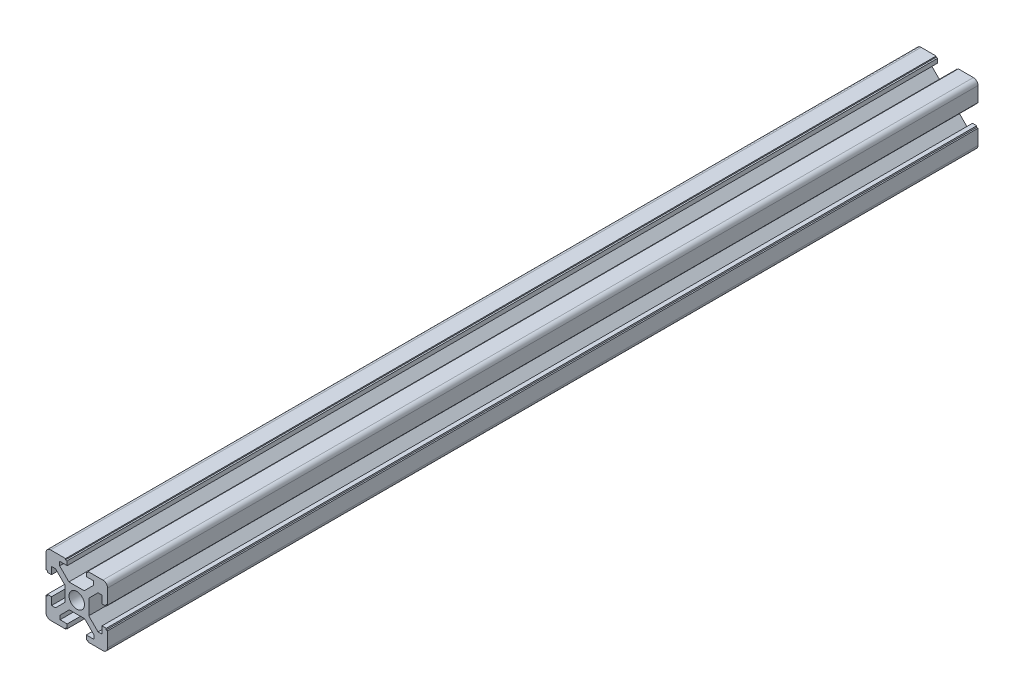
from build123d import *

# Parameters (mm, degrees)
SKETCH1_R           = 2.5
BOSS_EXTRUDE1_DEPTH = 283


with BuildPart() as part:
    # Sketch1 → Boss-Extrude1 (new body)
    with BuildSketch(Plane.XY):
        with BuildLine():
            Line((14.316619525, 10.387216168), (13.029112559, 10.387216168))
            Line((13.029112559, 10.387216168), (13.029112559, 12.855371932))
            Line((13.029112559, 12.855371932), (11.656738465, 12.855371932))
            Line((11.656738465, 12.855371932), (11.656738465, 12.336659272))
            Line((11.656738465, 12.336659272), (11.229112559, 12.336659272))
            Line((11.229112559, 12.336659272), (11.229112559, 7.521203168))
            ThreePointArc((11.229112559, 7.521203168), (11.668452387, 6.460542996), (12.729112559, 6.021203168))
            Line((12.729112559, 6.021203168), (17.624436699, 6.021203168))
            Line((17.624436699, 6.021203168), (17.624436699, 6.382997838))
            Line((17.624436699, 6.382997838), (18.129112559, 6.382997838))
            Line((18.129112559, 6.382997838), (18.129112559, 7.755371932))
            Line((18.129112559, 7.755371932), (15.794230869, 7.755371932))
            Line((15.794230869, 7.755371932), (15.794230869, 9.042878898))
            Line((15.794230869, 9.042878898), (18.806723903, 12.055371932))
            Line((18.806723903, 12.055371932), (23.784775289, 12.055371932))
            Line((23.784775289, 12.055371932), (26.797268323, 9.042878898))
            Line((26.797268323, 9.042878898), (26.797268323, 7.755371932))
            Line((26.797268323, 7.755371932), (24.329112559, 7.755371932))
            Line((24.329112559, 7.755371932), (24.329112559, 6.382997838))
            Line((24.329112559, 6.382997838), (24.847825219, 6.382997838))
            Line((24.847825219, 6.382997838), (24.847825219, 6.021203168))
            Line((24.847825219, 6.021203168), (29.729112559, 6.021203168))
            ThreePointArc((29.729112559, 6.021203168), (30.789772731, 6.460542996), (31.229112559, 7.521203168))
            Line((31.229112559, 7.521203168), (31.229112559, 12.350696072))
            Line((31.229112559, 12.350696072), (30.801486653, 12.350696072))
            Line((30.801486653, 12.350696072), (30.801486653, 12.855371932))
            Line((30.801486653, 12.855371932), (29.429112559, 12.855371932))
            Line((29.429112559, 12.855371932), (29.429112559, 10.520490242))
            Line((29.429112559, 10.520490242), (28.141605593, 10.520490242))
            Line((28.141605593, 10.520490242), (25.129112559, 13.532983276))
            Line((25.129112559, 13.532983276), (25.129112559, 18.511034662))
            Line((25.129112559, 18.511034662), (28.141605593, 21.523527696))
            Line((28.141605593, 21.523527696), (29.429112559, 21.523527696))
            Line((29.429112559, 21.523527696), (29.429112559, 19.055371932))
            Line((29.429112559, 19.055371932), (30.801486653, 19.055371932))
            Line((30.801486653, 19.055371932), (30.801486653, 19.574084592))
            Line((30.801486653, 19.574084592), (31.229112559, 19.574084592))
            Line((31.229112559, 19.574084592), (31.229112559, 24.389540696))
            ThreePointArc((31.229112559, 24.389540696), (30.789772731, 25.450200868), (29.729112559, 25.889540696))
            Line((29.729112559, 25.889540696), (24.833788419, 25.889540696))
            Line((24.833788419, 25.889540696), (24.833788419, 25.527746026))
            Line((24.833788419, 25.527746026), (24.329112559, 25.527746026))
            Line((24.329112559, 25.527746026), (24.329112559, 24.155371932))
            Line((24.329112559, 24.155371932), (26.663994249, 24.155371932))
            Line((26.663994249, 24.155371932), (26.663994249, 22.867864966))
            Line((26.663994249, 22.867864966), (23.651501215, 19.855371932))
            Line((23.651501215, 19.855371932), (18.673449829, 19.855371932))
            Line((18.673449829, 19.855371932), (15.660956795, 22.867864966))
            Line((15.660956795, 22.867864966), (15.660956795, 24.155371932))
            Line((15.660956795, 24.155371932), (18.129112559, 24.155371932))
            Line((18.129112559, 24.155371932), (18.129112559, 25.527746026))
            Line((18.129112559, 25.527746026), (17.610399899, 25.527746026))
            Line((17.610399899, 25.527746026), (17.610399899, 25.889540696))
            Line((17.610399899, 25.889540696), (12.729112559, 25.889540696))
            ThreePointArc((12.729112559, 25.889540696), (11.668452387, 25.450200868), (11.229112559, 24.389540696))
            Line((11.229112559, 24.389540696), (11.229112559, 19.560047792))
            Line((11.229112559, 19.560047792), (11.656738465, 19.560047792))
            Line((11.656738465, 19.560047792), (11.656738465, 19.055371932))
            Line((11.656738465, 19.055371932), (13.029112559, 19.055371932))
            Line((13.029112559, 19.055371932), (13.029112559, 21.390253622))
            Line((13.029112559, 21.390253622), (14.316619525, 21.390253622))
            Line((14.316619525, 21.390253622), (17.329112559, 18.377760588))
            Line((17.329112559, 18.377760588), (17.329112559, 13.399709202))
            Line((17.329112559, 13.399709202), (14.316619525, 10.387216168))
        make_face()
        with Locations((21.229112559, 15.955371932)):
            Circle(SKETCH1_R, mode=Mode.SUBTRACT)
    extrude(amount=BOSS_EXTRUDE1_DEPTH)


solid = part.part
